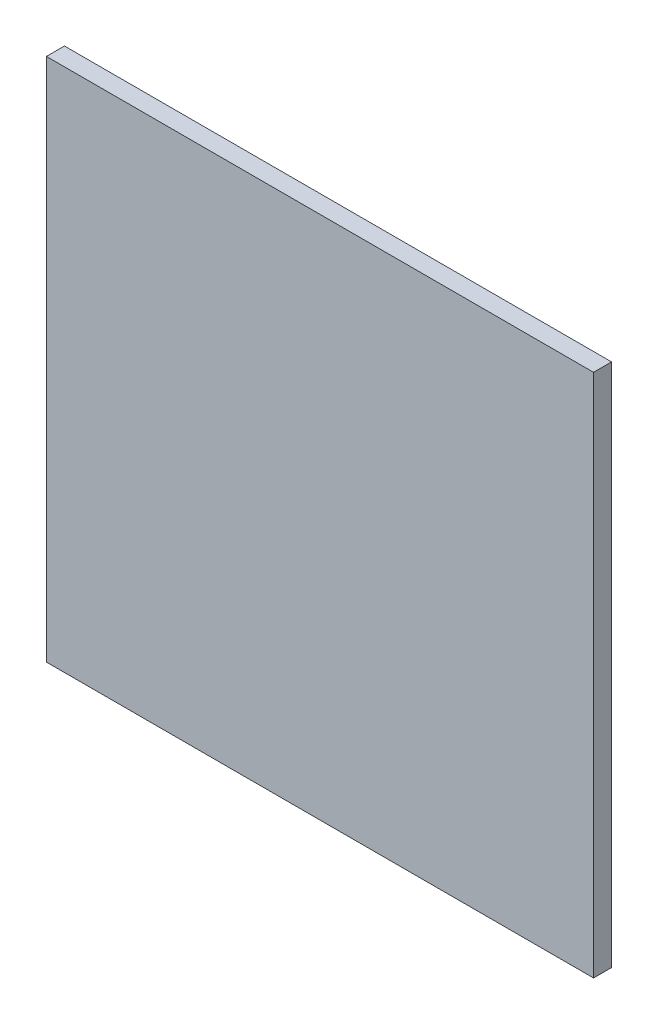
from build123d import *

# Parameters (mm, degrees)
SKETCH3_W                = 91
SKETCH3_H                = 87.244293111
BOSS_EXTRUDE1_DEPTH      = 2
BOSS_EXTRUDE1_DEPTH_BACK = 1


with BuildPart() as part:
    # Sketch3 → Boss-Extrude1 (new body, two sides)
    with BuildSketch(Plane.XY) as boss_extrude1_sk:
        with Locations((40.316463084, 38.577850393)):
            Rectangle(SKETCH3_W, SKETCH3_H)
    extrude(amount=BOSS_EXTRUDE1_DEPTH)
    extrude(boss_extrude1_sk.sketch, amount=-BOSS_EXTRUDE1_DEPTH_BACK)


solid = part.part
